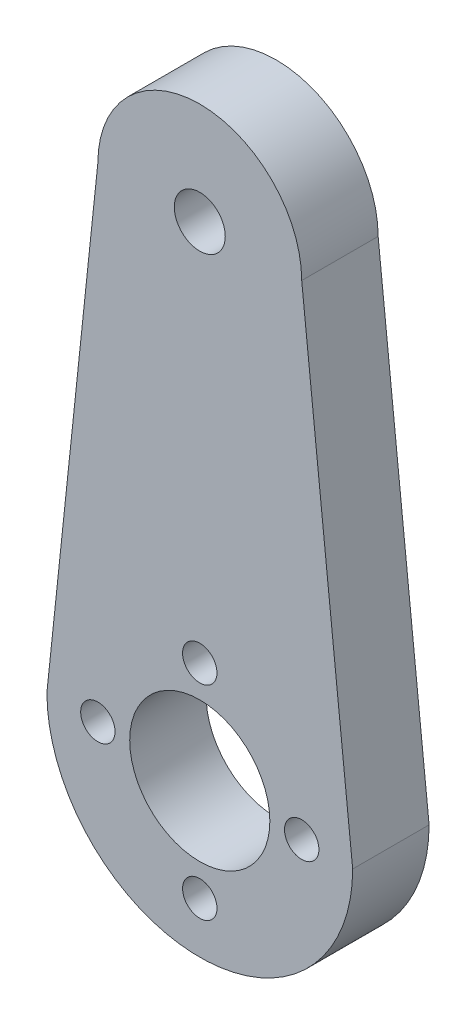
from build123d import *

# Parameters (mm, degrees)
BOSS_EXTRU_1_DEPTH           = 6
ESQUISSE2_R                  = 5.5
ESQUISSE2_R_2                = 1.35
ESQUISSE2_R_3                = 2
ENL_V_MAT_EXTRU_1_DEPTH      = 1
ENL_V_MAT_EXTRU_1_DEPTH_BACK = 7


with BuildPart() as part:
    # Esquisse1 → Boss.-Extru.1 (new body)
    with BuildSketch(Plane.XY):
        with BuildLine():
            Line((12, 0), (8, 38))
            ThreePointArc((8, 38), (0, 46), (-8, 38))
            Line((-8, 38), (-12, 0))
            ThreePointArc((-12, 0), (0, -12), (12, 0))
        make_face()
    extrude(amount=BOSS_EXTRU_1_DEPTH)

    # Esquisse2 → Enlèv. mat.-Extru.1 (cut, two sides)
    with BuildSketch(Plane.XY.offset(6)) as enl_v_mat_extru_1_sk:
        Circle(ESQUISSE2_R)
        with Locations((8, 0)):
            Circle(ESQUISSE2_R_2)
        with Locations((0, -8)):
            Circle(ESQUISSE2_R_2)
        with Locations((-8, 0)):
            Circle(ESQUISSE2_R_2)
        with Locations((0, 8)):
            Circle(ESQUISSE2_R_2)
        with Locations((0, 38)):
            Circle(ESQUISSE2_R_3)
    extrude(amount=ENL_V_MAT_EXTRU_1_DEPTH, mode=Mode.SUBTRACT)
    extrude(enl_v_mat_extru_1_sk.sketch, amount=-ENL_V_MAT_EXTRU_1_DEPTH_BACK, mode=Mode.SUBTRACT)


solid = part.part
